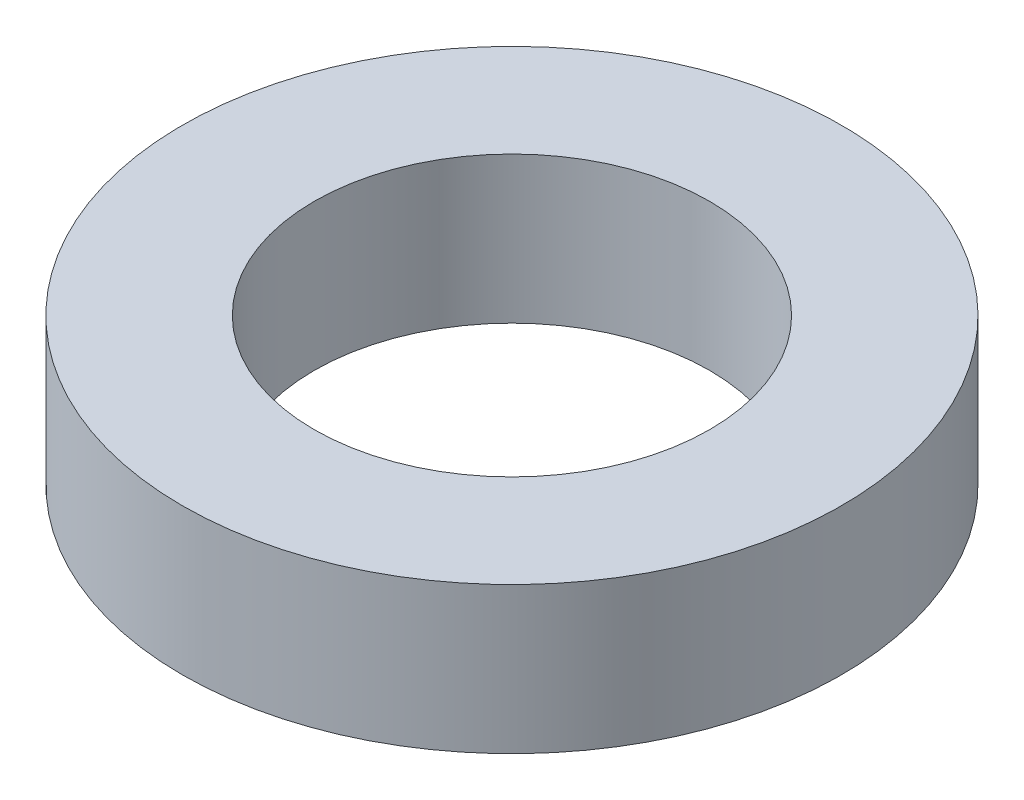
from build123d import *

# Parameters (mm, degrees)
SKETCH1_R           = 4.5
SKETCH1_R_2         = 2.7
BOSS_EXTRUDE1_DEPTH = 1


with BuildPart() as part:
    # Sketch1 → Boss-Extrude1 (new body, symmetric)
    with BuildSketch(Plane(origin=(0, 0, 0), x_dir=(1, 0, 0), z_dir=(0, 1, 0))):
        Circle(SKETCH1_R)
        Circle(SKETCH1_R_2, mode=Mode.SUBTRACT)
    extrude(amount=BOSS_EXTRUDE1_DEPTH, both=True)


solid = part.part
